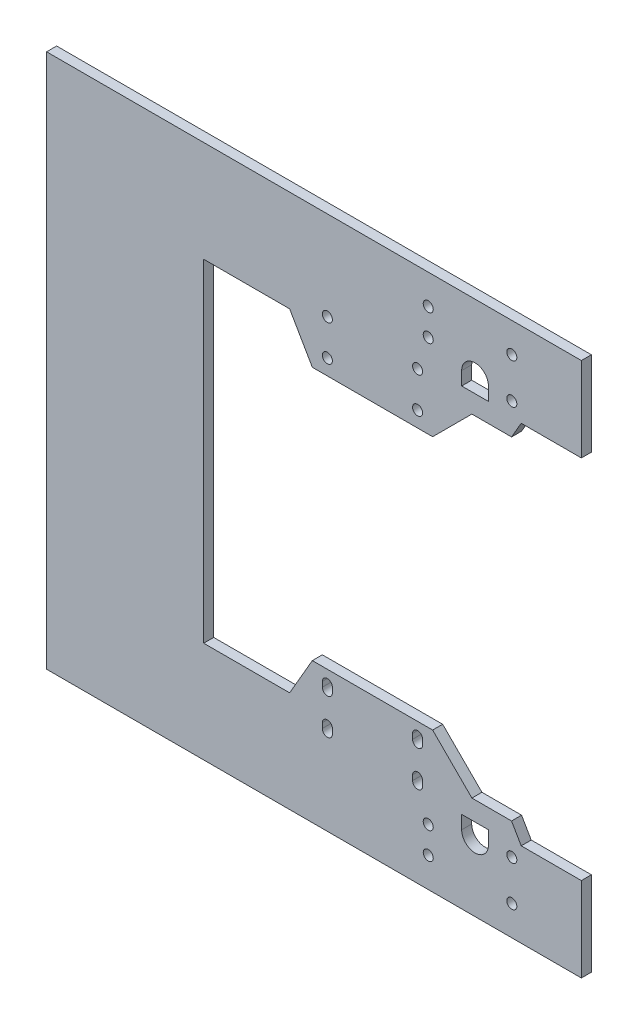
from build123d import *

# Parameters (mm, degrees)
BOSS_EXTRUDE1_DEPTH = 3
BOSS_EXTRUDE2_DEPTH = 3
CUT_EXTRUDE1_DEPTH  = 4
SKETCH5_R           = 1.5
CUT_EXTRUDE2_DEPTH  = 10
SKETCH7_R           = 4
CUT_EXTRUDE3_DEPTH  = 6
SKETCH8_R           = 1.5
CUT_EXTRUDE4_DEPTH  = 4
CUT_EXTRUDE5_DEPTH  = 10
CUT_EXTRUDE6_DEPTH  = 4


with BuildPart() as part:
    # Sketch2 → Boss-Extrude1 (new body)
    with BuildSketch(Plane.XY):
        Polygon((-110, 49.75), (3, 49.75), (3, 80), (-157, 80), (-157, -80), (3, -80), (3, -49.75), (-110, -49.75), align=None)
    extrude(amount=BOSS_EXTRUDE1_DEPTH)

    # Sketch3 → Boss-Extrude2 (add)
    with BuildSketch(Plane.XY.offset(3)):
        Polygon((-77.5, 38), (-41.5, 38), (-29.75, 49.75), (-84.283865663, 49.75), align=None)
        Polygon((-29.75, -49.75), (-84.283865663, -49.75), (-77.5, -38), (-41.5, -38), align=None)
    extrude(amount=-BOSS_EXTRUDE2_DEPTH)

    # Sketch4 → Cut-Extrude1 (cut, through all)
    with BuildSketch(Plane.XY.offset(3)):
        Polygon((-17.886751346, -49.75), (-15, -54.75), (3, -54.75), (3, -49.75), align=None)
        Polygon((-17.886751346, 49.75), (-15, 54.75), (3, 54.75), (3, 49.75), align=None)
    extrude(amount=-CUT_EXTRUDE1_DEPTH, mode=Mode.SUBTRACT)

    # Sketch5 → Cut-Extrude2 (cut)
    with BuildSketch(Plane.XY.offset(3)):
        with Locations((-73, -42.65)):
            Circle(SKETCH5_R)
        with Locations((-46, -42.65)):
            Circle(SKETCH5_R)
        with Locations((-46, -53.35)):
            Circle(SKETCH5_R)
        with Locations((-73, -53.35)):
            Circle(SKETCH5_R)
        with Locations((-46, 42.65)):
            Circle(SKETCH5_R)
        with Locations((-73, 42.65)):
            Circle(SKETCH5_R)
        with Locations((-73, 53.35)):
            Circle(SKETCH5_R)
        with Locations((-46, 53.35)):
            Circle(SKETCH5_R)
    extrude(amount=-CUT_EXTRUDE2_DEPTH, mode=Mode.SUBTRACT)

    # Sketch7 → Cut-Extrude3 (cut)
    with BuildSketch(Plane(origin=(0, 0, 0), x_dir=(-1, 0, 0), z_dir=(0, 0, -1))):
        with Locations((28.811352149, -59.5)):
            Circle(SKETCH7_R)
        with Locations((28.811352149, 59.5)):
            Circle(SKETCH7_R)
    extrude(amount=-CUT_EXTRUDE3_DEPTH, mode=Mode.SUBTRACT)

    # Sketch8 → Cut-Extrude4 (cut)
    with BuildSketch(Plane.XY.offset(3)):
        with Locations((-17.811352149, 59.1)):
            Circle(SKETCH8_R)
        with Locations((-17.811352149, 71.1)):
            Circle(SKETCH8_R)
        with Locations((-42.811352149, 63.1)):
            Circle(SKETCH8_R)
        with Locations((-42.811352149, 71.1)):
            Circle(SKETCH8_R)
        with Locations((-42.811352149, -71.1)):
            Circle(SKETCH8_R)
        with Locations((-42.811352149, -63.1)):
            Circle(SKETCH8_R)
        with Locations((-17.811352149, -59.1)):
            Circle(SKETCH8_R)
        with Locations((-17.811352149, -71.1)):
            Circle(SKETCH8_R)
    extrude(amount=-CUT_EXTRUDE4_DEPTH, mode=Mode.SUBTRACT)

    # Sketch9 → Cut-Extrude5 (cut)
    with BuildSketch(Plane(origin=(0, 0, 0), x_dir=(-1, 0, 0), z_dir=(0, 0, -1))):
        with BuildLine():
            Line((32.811352149, -55.5), (28.811352149, -55.5))
            ThreePointArc((28.811352149, -55.5), (31.639779274, -56.671572875), (32.811352149, -59.5))
            Line((32.811352149, -59.5), (32.811352149, -55.5))
        make_face()
        with BuildLine():
            Line((24.811352149, -55.5), (24.811352149, -59.5))
            ThreePointArc((24.811352149, -59.5), (25.982925025, -56.671572875), (28.811352149, -55.5))
            Line((28.811352149, -55.5), (24.811352149, -55.5))
        make_face()
        with BuildLine():
            ThreePointArc((28.811352149, 55.5), (25.982925025, 56.671572875), (24.811352149, 59.5))
            Line((24.811352149, 59.5), (24.811352149, 55.5))
            Line((24.811352149, 55.5), (28.811352149, 55.5))
        make_face()
        with BuildLine():
            Line((32.811352149, 55.5), (32.811352149, 59.5))
            ThreePointArc((32.811352149, 59.5), (31.639779274, 56.671572875), (28.811352149, 55.5))
            Line((28.811352149, 55.5), (32.811352149, 55.5))
        make_face()
    extrude(amount=-CUT_EXTRUDE5_DEPTH, mode=Mode.SUBTRACT)

    # Sketch10 → Cut-Extrude6 (cut, through all)
    with BuildSketch(Plane(origin=(0, 0, 0), x_dir=(-1, 0, 0), z_dir=(0, 0, -1))):
        with BuildLine():
            Line((71.5, -52.6), (71.5, -53.35))
            ThreePointArc((71.5, -53.35), (73, -51.85), (74.5, -53.35))
            Line((74.5, -53.35), (74.5, -52.6))
            ThreePointArc((74.5, -52.6), (73, -51.1), (71.5, -52.6))
        make_face()
        with BuildLine():
            Line((71.5, -53.35), (71.5, -54.1))
            ThreePointArc((71.5, -54.1), (73, -55.6), (74.5, -54.1))
            Line((74.5, -54.1), (74.5, -53.35))
            ThreePointArc((74.5, -53.35), (73, -54.85), (71.5, -53.35))
        make_face()
        with BuildLine():
            Line((74.5, -43.4), (74.5, -42.65))
            ThreePointArc((74.5, -42.65), (73, -44.15), (71.5, -42.65))
            Line((71.5, -42.65), (71.5, -43.4))
            ThreePointArc((71.5, -43.4), (73, -44.9), (74.5, -43.4))
        make_face()
        with BuildLine():
            Line((74.5, -42.65), (74.5, -41.9))
            ThreePointArc((74.5, -41.9), (73, -40.4), (71.5, -41.9))
            Line((71.5, -41.9), (71.5, -42.65))
            ThreePointArc((71.5, -42.65), (73, -41.15), (74.5, -42.65))
        make_face()
        with BuildLine():
            Line((47.5, -42.65), (47.5, -41.9))
            ThreePointArc((47.5, -41.9), (46, -40.4), (44.5, -41.9))
            Line((44.5, -41.9), (44.5, -42.65))
            ThreePointArc((44.5, -42.65), (46, -41.15), (47.5, -42.65))
        make_face()
        with BuildLine():
            Line((47.5, -43.4), (47.5, -42.65))
            ThreePointArc((47.5, -42.65), (46, -44.15), (44.5, -42.65))
            Line((44.5, -42.65), (44.5, -43.4))
            ThreePointArc((44.5, -43.4), (46, -44.9), (47.5, -43.4))
        make_face()
        with BuildLine():
            Line((44.5, -52.6), (44.5, -53.35))
            ThreePointArc((44.5, -53.35), (46, -51.85), (47.5, -53.35))
            Line((47.5, -53.35), (47.5, -52.6))
            ThreePointArc((47.5, -52.6), (46, -51.1), (44.5, -52.6))
        make_face()
        with BuildLine():
            Line((44.5, -53.35), (44.5, -54.1))
            ThreePointArc((44.5, -54.1), (46, -55.6), (47.5, -54.1))
            Line((47.5, -54.1), (47.5, -53.35))
            ThreePointArc((47.5, -53.35), (46, -54.85), (44.5, -53.35))
        make_face()
    extrude(amount=-CUT_EXTRUDE6_DEPTH, mode=Mode.SUBTRACT)


solid = part.part
